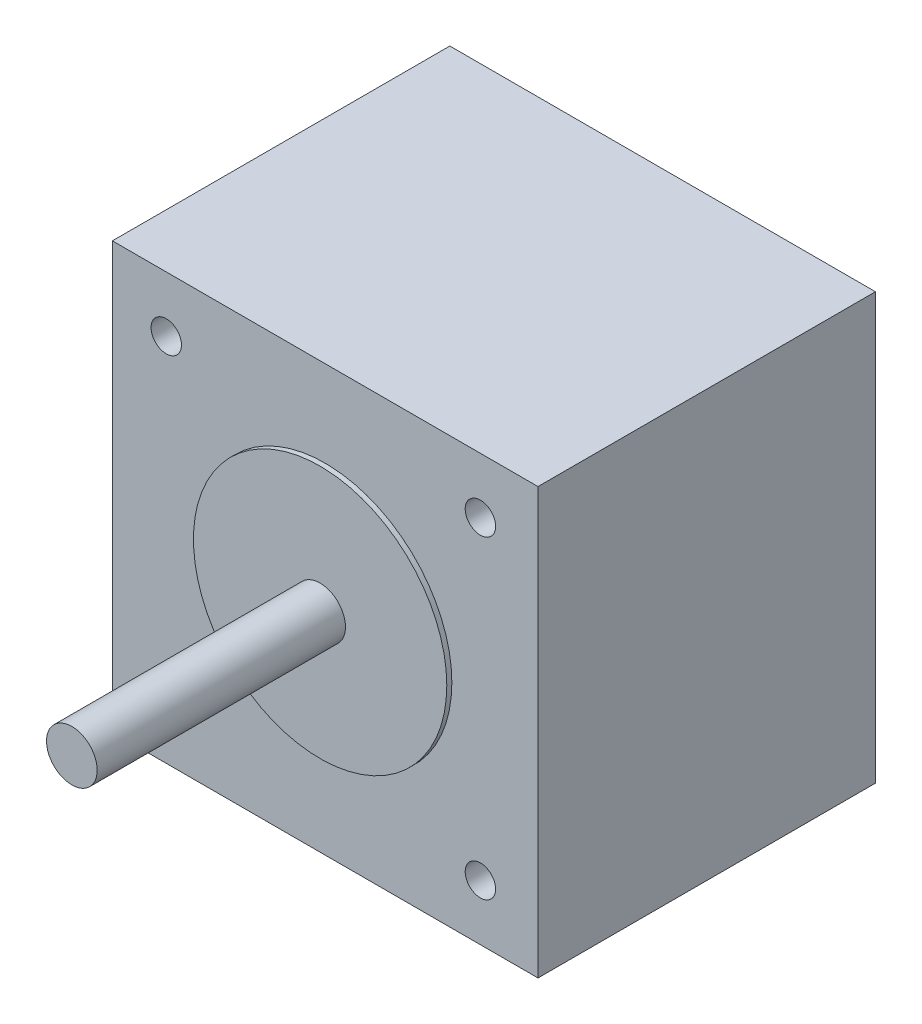
from build123d import *

# Parameters (mm, degrees)
SKETCH_1_W          = 42
SKETCH_1_H          = 42
EXTRUDE_1_DEPTH     = 33.3
SKETCH_2_R          = 12.5
EXTRUDE_2_DEPTH     = 0.5
SKETCH_3_R          = 1.5
CUT_EXTRUDE_1_DEPTH = 10
SKETCH_5_R          = 2.5
EXTRUDE_3_DEPTH     = 25


with BuildPart() as part:
    # ｽｹｯﾁ1 → ﾎﾞｽ - 押し出し1 (new body)
    with BuildSketch(Plane.XY):
        Rectangle(SKETCH_1_W, SKETCH_1_H)
    extrude(amount=EXTRUDE_1_DEPTH)

    # ｽｹｯﾁ2 → ﾎﾞｽ - 押し出し2 (add)
    with BuildSketch(Plane.XY.offset(33.3)):
        Circle(SKETCH_2_R)
    extrude(amount=EXTRUDE_2_DEPTH)

    # ｽｹｯﾁ3 → ｶｯﾄ - 押し出し1 (cut)
    with BuildSketch(Plane.XY.offset(33.3)):
        with Locations((-15.682538541, 15.5)):
            Circle(SKETCH_3_R)
        with Locations((-15.682538541, -15.5)):
            Circle(SKETCH_3_R)
        with Locations((15.317461459, -15.5)):
            Circle(SKETCH_3_R)
        with Locations((15.317461459, 15.5)):
            Circle(SKETCH_3_R)
    extrude(amount=-CUT_EXTRUDE_1_DEPTH, mode=Mode.SUBTRACT)

    # ｽｹｯﾁ5 → ﾎﾞｽ - 押し出し3 (add)
    with BuildSketch(Plane.XY.offset(33.3)):
        Circle(SKETCH_5_R)
    extrude(amount=EXTRUDE_3_DEPTH)


solid = part.part
